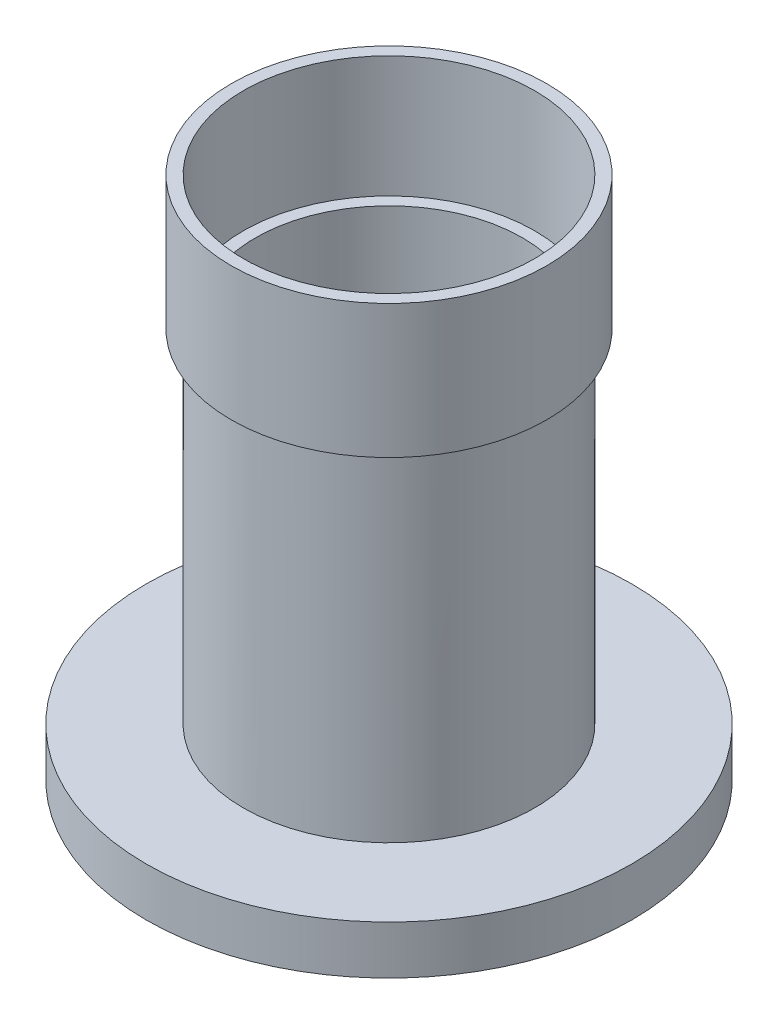
from build123d import *

# Parameters (mm, degrees)
SKETCH1_R           = 31.75
BOSS_EXTRUDE1_DEPTH = 6.35


with BuildPart() as part:
    # Sketch1 → Boss-Extrude1 (new body)
    with BuildSketch(Plane(origin=(0, 0, 0), x_dir=(1, 0, 0), z_dir=(0, 1, 0))):
        Circle(SKETCH1_R)
    extrude(amount=BOSS_EXTRUDE1_DEPTH)

    # Sketch2 → Revolve1 (revolve)
    with BuildSketch(Plane.XY):
        Polygon((19.05, 6.35), (19.05, 51.1175), (20.6375, 51.1175), (20.6375, 68.58), (19.05, 68.58), (19.05, 52.705), (17.4625, 52.705), (17.4625, 6.35), align=None)
    revolve(axis=Axis((0, -26.067472827, 0), (0, 1, 0)))


solid = part.part
